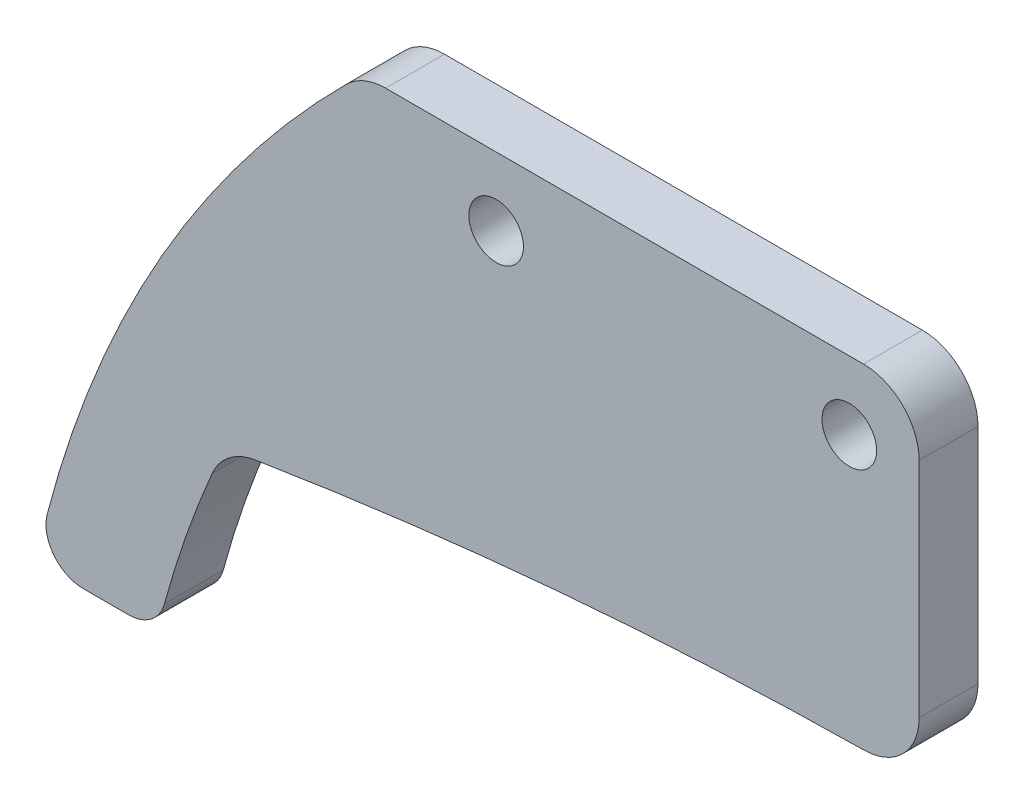
from build123d import *

# Parameters (mm, degrees)
BOSS_EXTRUDE1_DEPTH = 3.175
SKETCH2_R           = 1.4732
CUT_EXTRUDE1_DEPTH  = 4.175
FILLET1_R           = 3
FILLET3_R           = 2


with BuildPart() as part:
    # Sketch1 → Boss-Extrude1 (new body)
    with BuildSketch(Plane.XY):
        with BuildLine():
            Line((-17.122741189, 26.5), (-17.122741189, 44.5))
            Line((-17.122741189, 44.5), (-47.122741189, 44.5))
            ThreePointArc((-47.122741189, 44.5), (-58.300369938, 30.054224058), (-64.75017234, 12.965635))
            Line((-64.75017234, 12.965635), (-58.20928788, 12.965635))
            ThreePointArc((-58.20928788, 12.965635), (-56.652290629, 18.243467198), (-54.577718421, 23.340123288))
            ThreePointArc((-54.577718421, 23.340123288), (-35.916757127, 25.708630171), (-17.122741189, 26.5))
        make_face()
    extrude(amount=BOSS_EXTRUDE1_DEPTH)

    # Sketch2 → Cut-Extrude1 (cut, through all)
    with BuildSketch(Plane.XY.offset(3.175)):
        with Locations((-20.889565657, 40.81189221)):
            Circle(SKETCH2_R)
        with Locations((-39.939565657, 40.81189221)):
            Circle(SKETCH2_R)
    extrude(amount=-CUT_EXTRUDE1_DEPTH, mode=Mode.SUBTRACT)

    # Fillet1
    fillet1_edges = [part.edges().sort_by_distance(p)[0] for p in [
        (-47.122741189, 44.5, 1.5875),
        (-17.122741189, 44.5, 1.5875),
        (-17.122741189, 26.5, 1.5875),
        (-54.577718421, 23.340123288, 1.5875),
    ]]
    fillet(fillet1_edges, radius=FILLET1_R)

    # Fillet3
    fillet3_edges = [part.edges().sort_by_distance(p)[0] for p in [
        (-58.20928788, 12.965635, 1.5875),
        (-64.75017234, 12.965635, 1.5875),
    ]]
    fillet(fillet3_edges, radius=FILLET3_R)


solid = part.part
